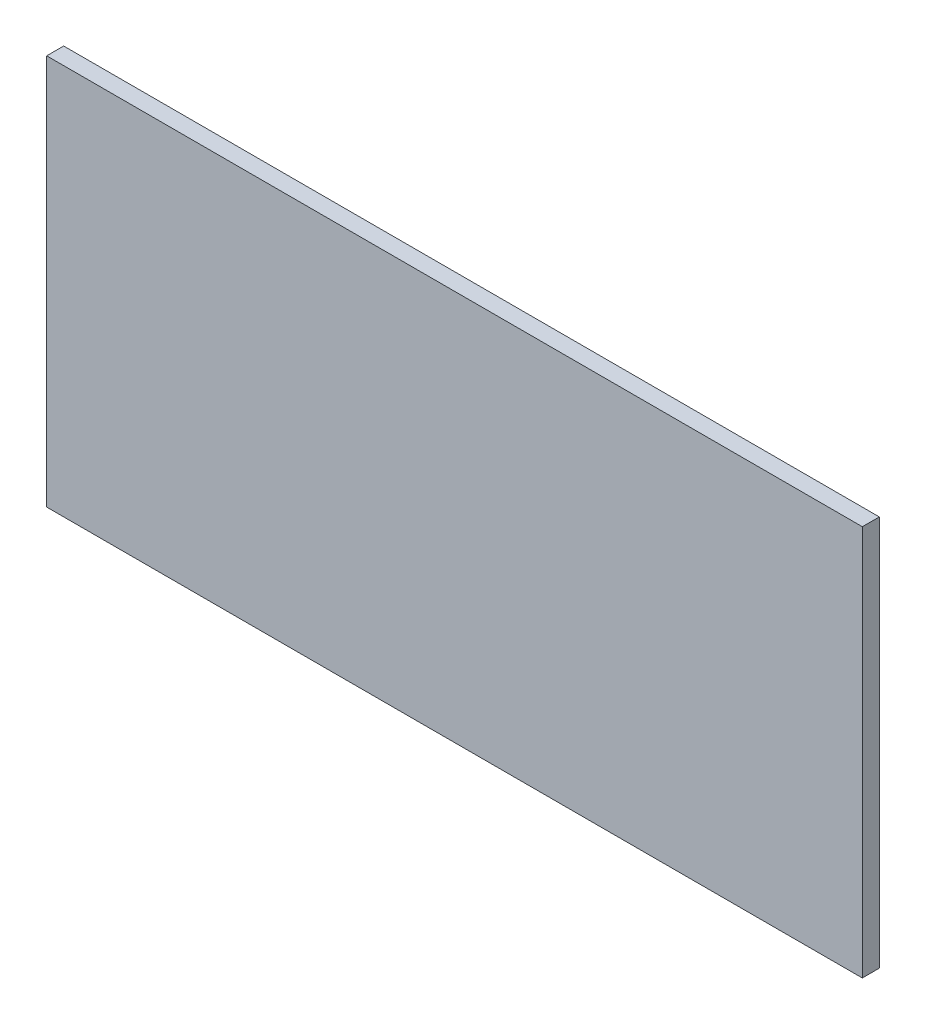
from build123d import *

# Parameters (mm, degrees)
SKETCH1_W           = 609.6
SKETCH1_H           = 292.1
BOSS_EXTRUDE1_DEPTH = 12.7


with BuildPart() as part:
    # Sketch1 → Boss-Extrude1 (new body)
    with BuildSketch(Plane.XY):
        with Locations((304.8, 146.05)):
            Rectangle(SKETCH1_W, SKETCH1_H)
    extrude(amount=BOSS_EXTRUDE1_DEPTH)


solid = part.part
